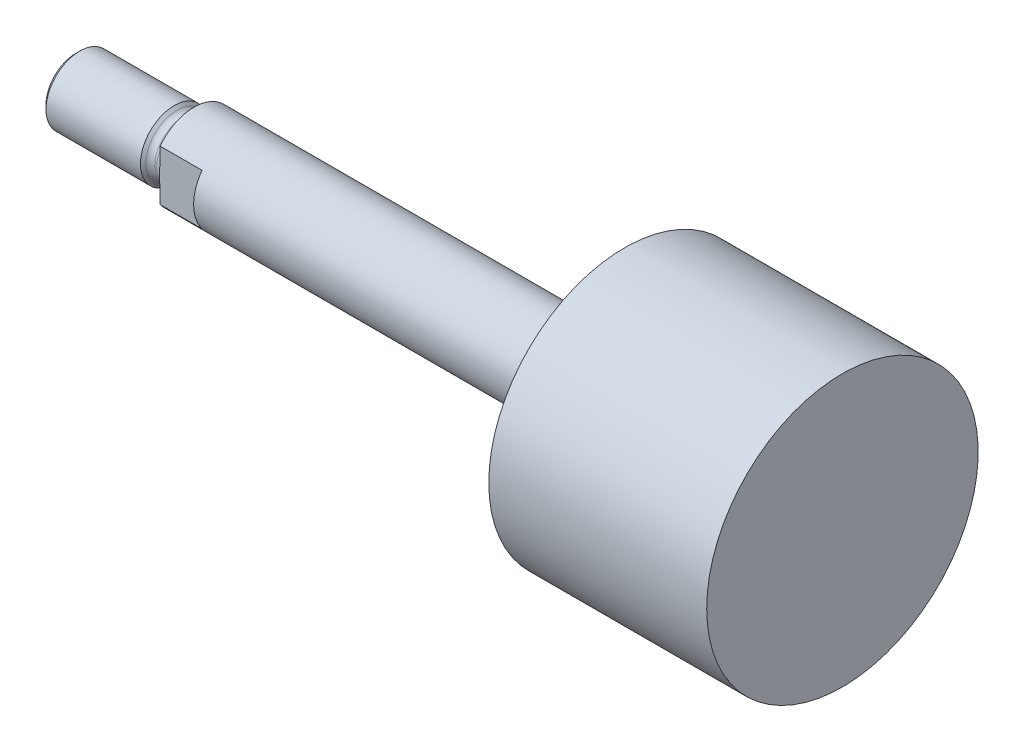
from build123d import *

# Parameters (mm, degrees)
SKETCH3_W          = 31.75
SKETCH3_H          = 31.75
SKETCH3_W_2        = 12.7
SKETCH3_H_2        = 15.875
CUT_EXTRUDE1_DEPTH = 8.509


with BuildPart() as part:
    # Sketch1 → Revolve1 (revolve)
    with BuildSketch(Plane.XY):
        Polygon((-9.525, 0), (-9.525, 7.9375), (71.4248, 7.9375), (71.4248, 25.52065), (112.395, 25.52065), (112.395, 0), align=None)
    revolve(axis=Axis((112.395, 0, 0), (-1, 0, 0)))

    # Sketch2 → Revolve2 (revolve)
    with BuildSketch(Plane.XY):
        with BuildLine():
            Line((-31.75, 0), (-31.75, 5.59435))
            Line((-31.75, 5.59435), (-30.99435, 6.35))
            Line((-30.99435, 6.35), (-13.2334, 6.35))
            Line((-13.2334, 6.35), (-12.726366704, 5.842966704))
            ThreePointArc((-12.726366704, 5.842966704), (-12.190743755, 5.485074892), (-11.558933409, 5.3594))
            Line((-11.558933409, 5.3594), (-11.176, 5.3594))
            ThreePointArc((-11.176, 5.3594), (-10.008566704, 5.842966704), (-9.525, 7.0104))
            Line((-9.525, 7.0104), (-9.525, 0))
            Line((-9.525, 0), (-31.75, 0))
        make_face()
    revolve(axis=Axis((-9.525, 0, 0), (-1, 0, 0)))

    # Sketch3 → Cut-Extrude1 (cut)
    with BuildSketch(Plane(origin=(-10.16, 0, 0), x_dir=(0, 0, -1), z_dir=(1, 0, 0))):
        Rectangle(SKETCH3_W, SKETCH3_H)
        Rectangle(SKETCH3_W_2, SKETCH3_H_2, mode=Mode.SUBTRACT)
    extrude(amount=CUT_EXTRUDE1_DEPTH, mode=Mode.SUBTRACT)


solid = part.part
